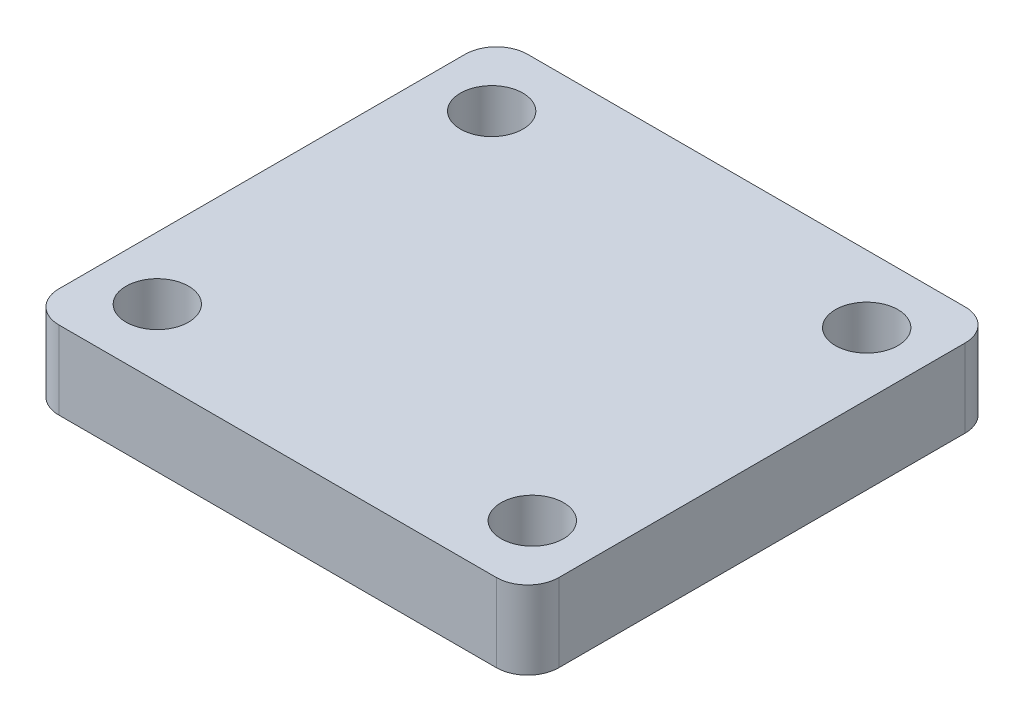
from build123d import *

# Parameters (mm, degrees)
EXTRUDE_5_DEPTH    = 5
SKETCH2_R          = 2
CUT_EXTRUDE1_DEPTH = 5


with BuildPart() as part:
    # Sketch1 → Extrude 5 (new body)
    with BuildSketch(Plane(origin=(0, 0, 0), x_dir=(1, 0, 0), z_dir=(0, 1, 0))):
        with BuildLine():
            Line((14, -15), (-14, -15))
            ThreePointArc((-14, -15), (-15.414213562, -14.414213562), (-16, -13))
            Line((-16, -13), (-16, 13))
            ThreePointArc((-16, 13), (-15.414213562, 14.414213562), (-14, 15))
            Line((-14, 15), (14, 15))
            ThreePointArc((14, 15), (15.414213562, 14.414213562), (16, 13))
            Line((16, 13), (16, -13))
            ThreePointArc((16, -13), (15.414213562, -14.414213562), (14, -15))
        make_face()
    extrude(amount=EXTRUDE_5_DEPTH)

    # Sketch2 → Cut-Extrude1 (cut)
    with BuildSketch(Plane(origin=(0, 5, 0), x_dir=(1, 0, 0), z_dir=(0, 1, 0))):
        with Locations((-12, 10.7)):
            Circle(SKETCH2_R)
        with Locations((12, 10.7)):
            Circle(SKETCH2_R)
        with Locations((12, -10.7)):
            Circle(SKETCH2_R)
        with Locations((-12, -10.7)):
            Circle(SKETCH2_R)
    extrude(amount=-CUT_EXTRUDE1_DEPTH, mode=Mode.SUBTRACT)


solid = part.part
